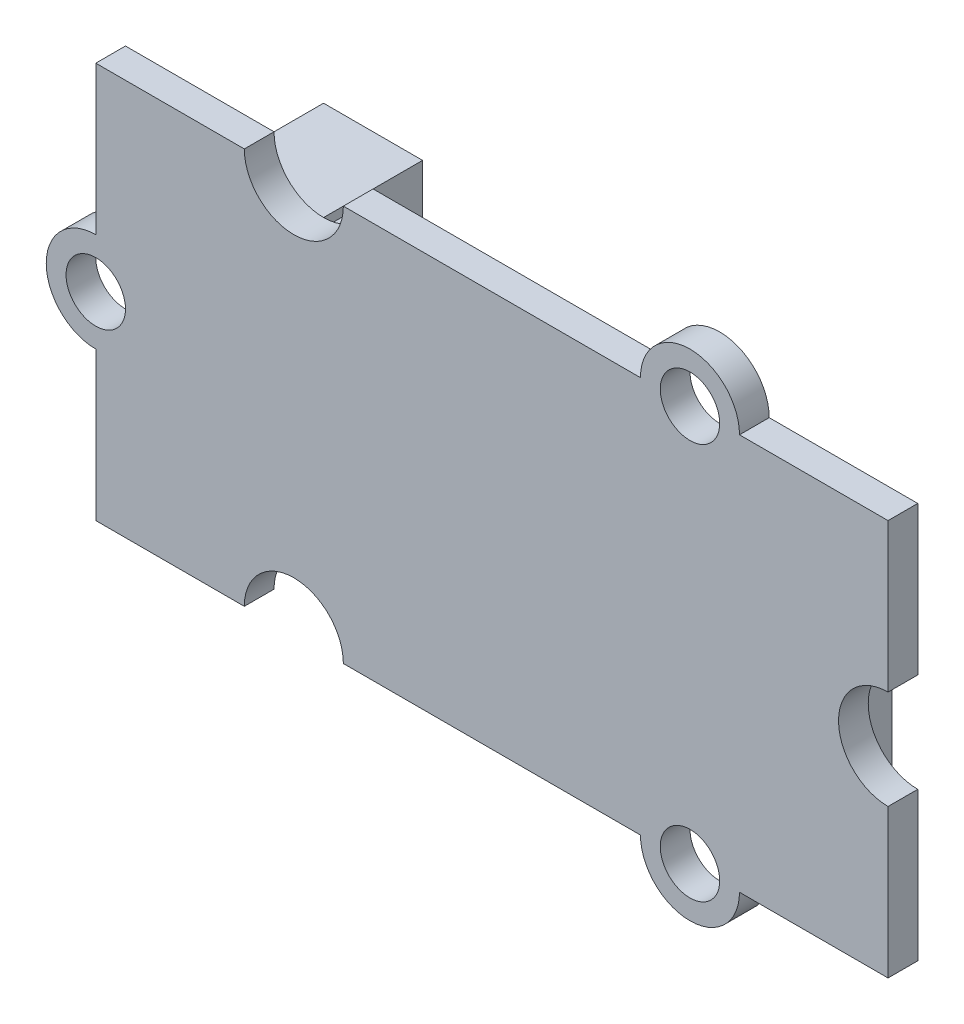
from build123d import *

# Parameters (mm, degrees)
SKIZZE1_W                       = 40
SKIZZE1_H                       = 20
AUFSATZ_LINEAR_AUSTRAGEN1_DEPTH = 1.5
SKIZZE2_R                       = 2.5
SCHNITT_LINEAR_AUSTRAGEN1_DEPTH = 2.5
SKIZZE3_R                       = 2.5
SCHNITT_LINEAR_AUSTRAGEN2_DEPTH = 2.5
SKIZZE4_R                       = 2.5
AUFSATZ_LINEAR_AUSTRAGEN2_DEPTH = 1.5
SKIZZE5_R                       = 2.5
AUFSATZ_LINEAR_AUSTRAGEN3_DEPTH = 1.5
SKIZZE6_R                       = 1.5
SCHNITT_LINEAR_AUSTRAGEN3_DEPTH = 2.5
SKIZZE7_W                       = 27.5
SKIZZE7_H                       = 13.5
AUFSATZ_LINEAR_AUSTRAGEN4_DEPTH = 1.5
SKIZZE8_W                       = 5
SKIZZE8_H                       = 10
AUFSATZ_LINEAR_AUSTRAGEN5_DEPTH = 7.5
WANDUNG1_T                      = -0.5
SKIZZE10_R                      = 0.75
AUFSATZ_LINEAR_AUSTRAGEN6_DEPTH = 6.5
VERRUNDUNG1_R                   = 0.5


with BuildPart() as part:
    # Skizze1 → Aufsatz-Linear austragen1 (new body)
    with BuildSketch(Plane.XY):
        Rectangle(SKIZZE1_W, SKIZZE1_H)
    extrude(amount=AUFSATZ_LINEAR_AUSTRAGEN1_DEPTH)

    # Skizze2 → Schnitt-Linear austragen1 (cut, through all)
    with BuildSketch(Plane.XY.offset(1.5)):
        with Locations((20, 0)):
            Circle(SKIZZE2_R)
    extrude(amount=-SCHNITT_LINEAR_AUSTRAGEN1_DEPTH, mode=Mode.SUBTRACT)

    # Skizze3 → Schnitt-Linear austragen2 (cut, through all)
    with BuildSketch(Plane.XY.offset(1.5)):
        with Locations((-10, 10)):
            Circle(SKIZZE3_R)
        with Locations((-10, -10)):
            Circle(SKIZZE3_R)
    extrude(amount=-SCHNITT_LINEAR_AUSTRAGEN2_DEPTH, mode=Mode.SUBTRACT)

    # Skizze4 → Aufsatz-Linear austragen2 (add)
    with BuildSketch(Plane.XY.offset(1.5)):
        with Locations((10, 10)):
            Circle(SKIZZE4_R)
        with Locations((10, -10)):
            Circle(SKIZZE4_R)
    extrude(amount=-AUFSATZ_LINEAR_AUSTRAGEN2_DEPTH)

    # Skizze5 → Aufsatz-Linear austragen3 (add)
    with BuildSketch(Plane(origin=(0, 0, 0), x_dir=(-1, 0, 0), z_dir=(0, 0, -1))):
        with Locations((20, 0)):
            Circle(SKIZZE5_R)
    extrude(amount=-AUFSATZ_LINEAR_AUSTRAGEN3_DEPTH)

    # Skizze6 → Schnitt-Linear austragen3 (cut, through all)
    with BuildSketch(Plane.XY.offset(1.5)):
        with Locations((-20, 0)):
            Circle(SKIZZE6_R)
        with Locations((10, 10)):
            Circle(SKIZZE6_R)
        with Locations((10, -10)):
            Circle(SKIZZE6_R)
    extrude(amount=-SCHNITT_LINEAR_AUSTRAGEN3_DEPTH, mode=Mode.SUBTRACT)


with BuildPart() as body_2:
    # Skizze7 → Aufsatz-Linear austragen4 (new body)
    with BuildSketch(Plane(origin=(0, 0, 0), x_dir=(-1, 0, 0), z_dir=(0, 0, -1))):
        with Locations((-3.45, 0)):
            Rectangle(SKIZZE7_W, SKIZZE7_H)
    extrude(amount=AUFSATZ_LINEAR_AUSTRAGEN4_DEPTH)


with BuildPart() as body_3:
    # Skizze8 → Aufsatz-Linear austragen5 (new body)
    with BuildSketch(Plane(origin=(0, 0, 0), x_dir=(-1, 0, 0), z_dir=(0, 0, -1))):
        with Locations((15, 0)):
            Rectangle(SKIZZE8_W, SKIZZE8_H)
    extrude(amount=AUFSATZ_LINEAR_AUSTRAGEN5_DEPTH)

    # Wandung1
    wandung1_openings = [body_3.faces().sort_by_distance(p)[0] for p in [
        (-15, 0, -7.5),
    ]]
    offset(amount=WANDUNG1_T, openings=wandung1_openings, kind=Kind.INTERSECTION)

    # Skizze10 → Aufsatz-Linear austragen6 (add)
    with BuildSketch(Plane(origin=(0, 0, -0.5), x_dir=(-1, 0, 0), z_dir=(0, 0, -1))):
        with Locations((15, -2.75)):
            Circle(SKIZZE10_R)
        with Locations((15, -0.75)):
            Circle(SKIZZE10_R)
        with Locations((15, 1.25)):
            Circle(SKIZZE10_R)
        with Locations((15, 3.25)):
            Circle(SKIZZE10_R)
    extrude(amount=AUFSATZ_LINEAR_AUSTRAGEN6_DEPTH)

    # Verrundung1
    verrundung1_edges = [body_3.edges().sort_by_distance(p)[0] for p in [
        (-14.25, -2.75, -7),
        (-14.25, -0.75, -7),
        (-14.25, 1.25, -7),
        (-14.25, 3.25, -7),
    ]]
    fillet(verrundung1_edges, radius=VERRUNDUNG1_R)


solid = Compound([part.part, body_2.part, body_3.part])
